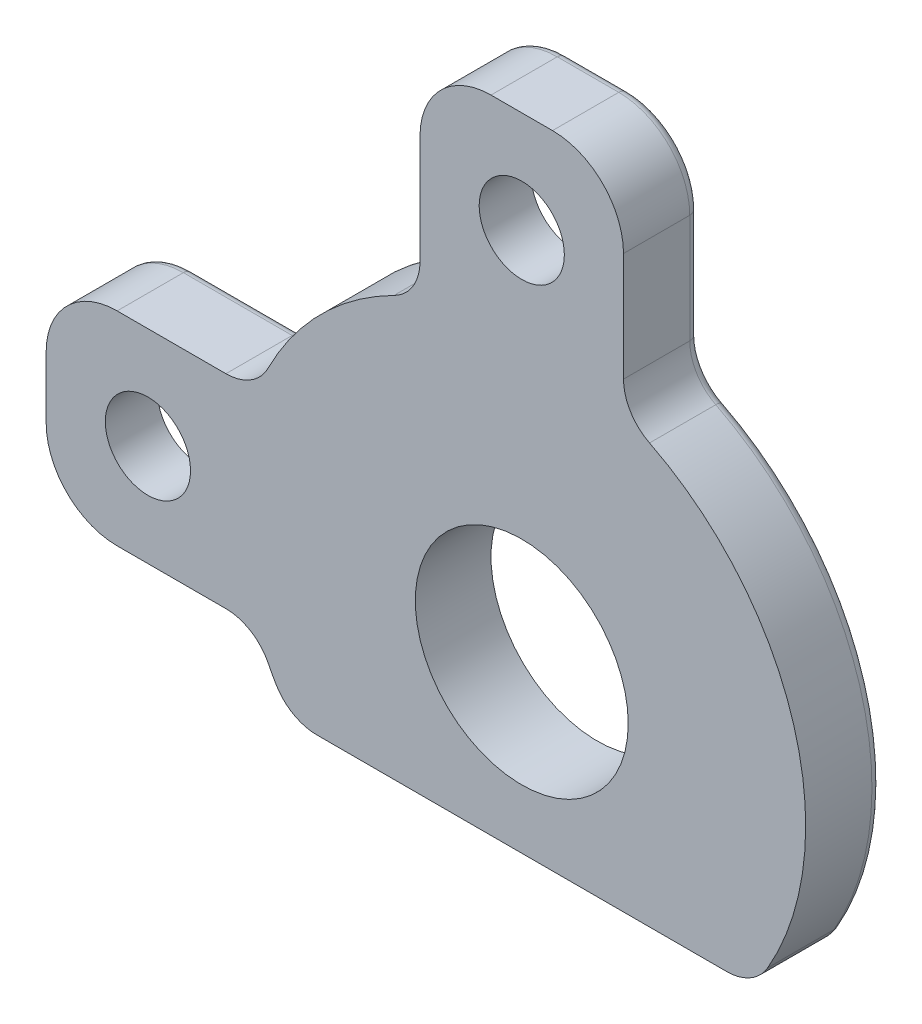
from build123d import *

# Parameters (mm, degrees)
SKETCH10_R          = 4.5
BOSS_EXTRUDE6_DEPTH = 1.6
SKETCH13_R          = 1.8
BOSS_EXTRUDE7_DEPTH = 1.6
FILLET1_R           = 2
CUT_EXTRUDE2_DEPTH  = 1
SKETCH16_R          = 3
CUT_EXTRUDE3_DEPTH  = 1
CHAMFER1_SIZE       = 0.5
FILLET2_R           = 0.4


with BuildPart() as part:
    # Sketch10 → Boss-Extrude6 (new body, symmetric)
    with BuildSketch(Plane.XY):
        with BuildLine():
            Line((-9.746794345, -7), (9.746794345, -7))
            ThreePointArc((9.746794345, -7), (0, 12), (-9.746794345, -7))
        make_face()
        Circle(SKETCH10_R, mode=Mode.SUBTRACT)
    extrude(amount=BOSS_EXTRUDE6_DEPTH, both=True)

    # Sketch13 → Boss-Extrude7 (add, symmetric)
    with BuildSketch(Plane.XY):
        with BuildLine():
            Line((-11.203124564, 4.3), (-17.1, 4.3))
            ThreePointArc((-17.1, 4.3), (-19.221320344, 3.421320344), (-20.1, 1.3))
            Line((-20.1, 1.3), (-20.1, -1.3))
            ThreePointArc((-20.1, -1.3), (-19.221320344, -3.421320344), (-17.1, -4.3))
            Line((-17.1, -4.3), (-11.203124564, -4.3))
            ThreePointArc((-11.203124564, -4.3), (-12, 0), (-11.203124564, 4.3))
        make_face()
        with Locations((-15.8, 0)):
            Circle(SKETCH13_R, mode=Mode.SUBTRACT)
        with BuildLine():
            Line((4.3, 11.203124564), (4.3, 17.1))
            ThreePointArc((4.3, 17.1), (3.421320344, 19.221320344), (1.3, 20.1))
            Line((1.3, 20.1), (-1.3, 20.1))
            ThreePointArc((-1.3, 20.1), (-3.421320344, 19.221320344), (-4.3, 17.1))
            Line((-4.3, 17.1), (-4.3, 11.203124564))
            ThreePointArc((-4.3, 11.203124564), (0, 12), (4.3, 11.203124564))
        make_face()
        with Locations((0, 15.8)):
            Circle(SKETCH13_R, mode=Mode.SUBTRACT)
    extrude(amount=BOSS_EXTRUDE7_DEPTH, both=True)

    # Fillet1
    fillet1_edges = [part.edges().sort_by_distance(p)[0] for p in [
        (-11.203124564, -4.3, 0),
        (-11.203124564, 4.3, 0),
        (-4.3, 11.203124564, 0),
        (4.3, 11.203124564, 0),
        (9.746794345, -7, 0),
        (-9.746794345, -7, 0),
    ]]
    fillet(fillet1_edges, radius=FILLET1_R)

    # Sketch15 → Cut-Extrude2 (cut)
    with BuildSketch(Plane(origin=(0, 0, -1.6), x_dir=(-1, 0, 0), z_dir=(0, 0, -1))):
        with BuildLine():
            Line((-3.808047036, 8.187368684), (-7.070755069, 6.665942941))
            ThreePointArc((-7.070755069, 6.665942941), (-7.329292249, 6.38379912), (-7.312599832, 6.001479917))
            Line((-7.312599832, 6.001479917), (-6.847719744, 5.004541351))
            ThreePointArc((-6.847719744, 5.004541351), (-6.565575922, 4.746004172), (-6.18325672, 4.762696589))
            Line((-6.18325672, 4.762696589), (-2.920548686, 6.284122331))
            ThreePointArc((-2.920548686, 6.284122331), (-2.662011507, 6.566266153), (-2.678703924, 6.948585355))
            Line((-2.678703924, 6.948585355), (-3.143584012, 7.945523921))
            ThreePointArc((-3.143584012, 7.945523921), (-3.425727833, 8.204061101), (-3.808047036, 8.187368684))
        make_face()
        with BuildLine():
            Line((6.847719744, 5.004541351), (7.312599832, 6.001479917))
            ThreePointArc((7.312599832, 6.001479917), (7.329292249, 6.38379912), (7.070755069, 6.665942941))
            Line((7.070755069, 6.665942941), (3.808047036, 8.187368684))
            ThreePointArc((3.808047036, 8.187368684), (3.425727833, 8.204061101), (3.143584012, 7.945523921))
            Line((3.143584012, 7.945523921), (2.678703924, 6.948585355))
            ThreePointArc((2.678703924, 6.948585355), (2.662011507, 6.566266153), (2.920548686, 6.284122331))
            Line((2.920548686, 6.284122331), (6.18325672, 4.762696589))
            ThreePointArc((6.18325672, 4.762696589), (6.565575922, 4.746004172), (6.847719744, 5.004541351))
        make_face()
    extrude(amount=-CUT_EXTRUDE2_DEPTH, mode=Mode.SUBTRACT)

    # Sketch16 → Cut-Extrude3 (cut)
    with BuildSketch(Plane(origin=(0, 0, -1.6), x_dir=(-1, 0, 0), z_dir=(0, 0, -1))):
        with Locations((0, 15.8)):
            Circle(SKETCH16_R)
        with Locations((15.8, 0)):
            Circle(SKETCH16_R)
    extrude(amount=-CUT_EXTRUDE3_DEPTH, mode=Mode.SUBTRACT)

    # Chamfer1
    chamfer1_edges = [part.edges().sort_by_distance(p)[0] for p in [
        (3, 15.8, -1.6),
        (-12.8, 0, -1.6),
    ]]
    chamfer(chamfer1_edges, length=CHAMFER1_SIZE)

    # Fillet2
    fillet2_edges = [part.edges().sort_by_distance(p)[0] for p in [
        (-19.221320344, 3.421320344, -1.6),
        (-20.1, 0, -1.6),
        (-19.221320344, -3.421320344, -1.6),
        (-14.801199885, -4.3, -1.6),
        (3.421320344, 19.221320344, -1.6),
        (0, 20.1, -1.6),
        (-3.421320344, 19.221320344, -1.6),
        (-4.3, 14.801199885, -1.6),
        (-14.801199885, 4.3, -1.6),
        (-8.485281374, 8.485281374, -1.6),
        (4.3, 14.801199885, -1.6),
        (11.498184685, 3.433911609, -1.6),
        (-10.558586547, -5.702302178, -1.6),
        (0, -7, -1.6),
        (-9.660254038, -6.732050808, -1.6),
        (9.660254038, -6.732050808, -1.6),
        (-11.453590921, 4.597061363, -1.6),
        (4.597061363, 11.453590921, -1.6),
        (-4.597061363, 11.453590921, -1.6),
        (-11.453590921, -4.597061363, -1.6),
    ]]
    fillet(fillet2_edges, radius=FILLET2_R)


solid = part.part
